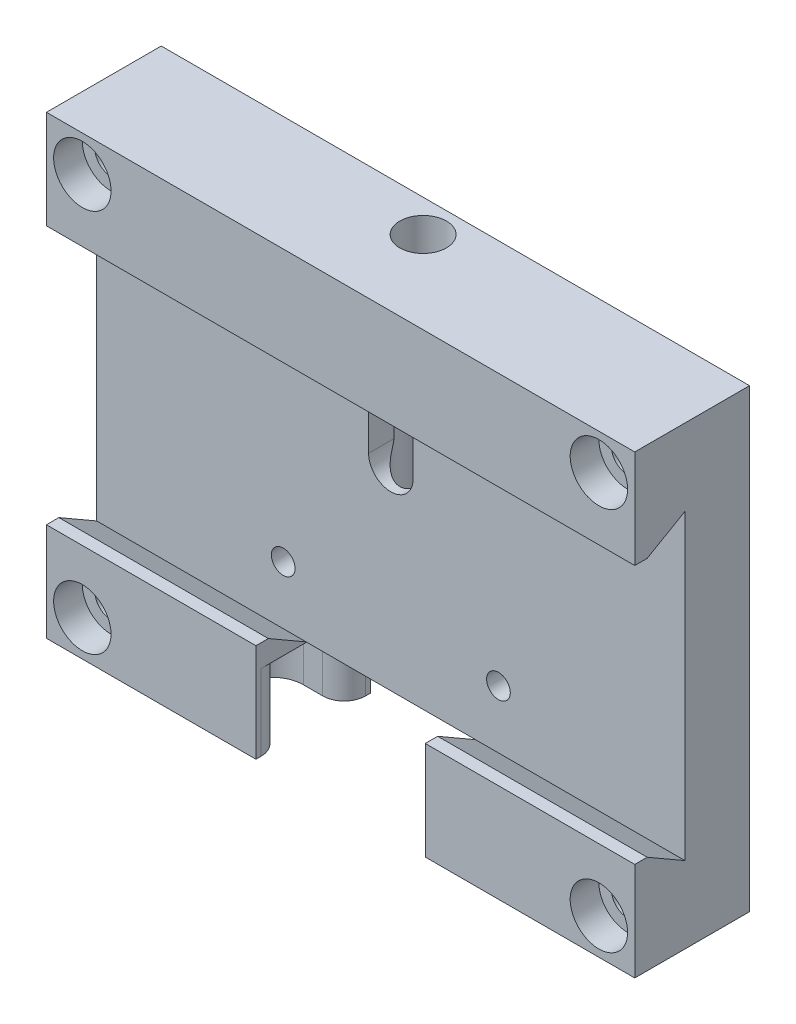
from build123d import *

# Parameters (mm, degrees)
SKETCH_1_W                  = 82
SKETCH_1_H                  = 63.5
EXTRUDE_1_DEPTH             = 16
CUT_EXTRUDE_1_DEPTH         = 83
SKETCH_15_W                 = 23.6
SKETCH_15_H                 = 14.711451884
CUT_EXTRUDE_4_DEPTH         = 7
SKETCH_16_W                 = 23.6
SKETCH_16_H                 = 10.67
CUT_EXTRUDE_5_DEPTH         = 9
SKETCH_17_R                 = 2.5
CUT_EXTRUDE_6_DEPTH         = 8
M4X0_72_D                   = 3.3
M4X0_72_DEPTH               = 10
M4X0_72_TIP                 = 0.991420021
CUT_EXTRUDE_7_DEPTH         = 4
SKETCH_26_R                 = 3.25
CUT_EXTRUDE_8_DEPTH         = 38
HOLE_WIZARD_M41_D           = 4.5
HOLE_WIZARD_M41_CBORE_D     = 8
HOLE_WIZARD_M41_CBORE_DEPTH = 4
CHAMFER_2_SIZE              = 1
CHAMFER_2_SIZE2             = 2
CHAMFER_2_PART_2_SIZE       = 1
CHAMFER_2_PART_2_SIZE2      = 2
CHAMFER_2_PART_3_SIZE       = 1
CHAMFER_2_PART_3_SIZE2      = 2
CUT_EXTRUDE_12_DEPTH        = 10.6
FILLET_1_R                  = 3
M4X0_73_D                   = 3.3


with BuildPart() as part:
    # Эскиз1 → Бобышка-Вытянуть1 (new body)
    with BuildSketch(Plane.XY):
        with Locations((41, -31.75)):
            Rectangle(SKETCH_1_W, SKETCH_1_H)
    extrude(amount=EXTRUDE_1_DEPTH)

    # Эскиз2 → Вырез-Вытянуть1 (cut, through all)
    with BuildSketch(Plane.ZY):
        Polygon((9, -10.67), (16, -14.711451884), (16, -48.788548116), (9, -52.83), align=None)
    extrude(amount=-CUT_EXTRUDE_1_DEPTH, mode=Mode.SUBTRACT)

    # Эскиз15 → Вырез-Вытянуть4 (cut)
    with BuildSketch(Plane.XY.offset(16)):
        with Locations((41, -56.144274058)):
            Rectangle(SKETCH_15_W, SKETCH_15_H)
    extrude(amount=-CUT_EXTRUDE_4_DEPTH, mode=Mode.SUBTRACT)

    # Эскиз16 → Вырез-Вытянуть5 (cut)
    with BuildSketch(Plane.XY.offset(9)):
        with Locations((41, -58.165)):
            Rectangle(SKETCH_16_W, SKETCH_16_H)
    extrude(amount=-CUT_EXTRUDE_5_DEPTH, mode=Mode.SUBTRACT)

    # Эскиз17 → Вырез-Вытянуть6 (cut)
    with BuildSketch(Plane.XZ.offset(52.83)):
        with Locations((33.5, 5)):
            Circle(SKETCH_17_R)
        with Locations((48.5, 5)):
            Circle(SKETCH_17_R)
    extrude(amount=-CUT_EXTRUDE_6_DEPTH, mode=Mode.SUBTRACT)

    # Отверстие обработанное метчиком M4x0.72
    with Locations(Plane(origin=(0, -52.83, 0), x_dir=(-1, 0, 0), z_dir=(0, -1, 0))):
        with Locations((-41, -5)):
            Hole(M4X0_72_D / 2, depth=M4X0_72_DEPTH)
            with Locations((0, 0, -(M4X0_72_DEPTH + M4X0_72_TIP / 2))):  # 118° drill point
                Cone(0, M4X0_72_D / 2, M4X0_72_TIP, mode=Mode.SUBTRACT)

    # Эскиз25 → Вырез-Вытянуть7 (cut)
    with BuildSketch(Plane.XY.offset(9)):
        with BuildLine():
            Line((44.1, -18.711451884), (44.1, -25.711451884))
            ThreePointArc((44.1, -25.711451884), (41, -28.811451884), (37.9, -25.711451884))
            Line((37.9, -25.711451884), (37.9, -18.711451884))
            ThreePointArc((37.9, -18.711451884), (41, -15.611451884), (44.1, -18.711451884))
        make_face()
    extrude(amount=-CUT_EXTRUDE_7_DEPTH, mode=Mode.SUBTRACT)

    # Эскиз26 → Вырез-Вытянуть8 (cut)
    with BuildSketch(Plane(origin=(0, 0, 0), x_dir=(1, 0, 0), z_dir=(0, 1, 0))):
        with Locations((41, -4.5)):
            Circle(SKETCH_26_R)
    extrude(amount=-CUT_EXTRUDE_8_DEPTH, mode=Mode.SUBTRACT)

    # Цековка для винта с внутренним шестигранником M41 (through all)
    with Locations(Plane(origin=(30.759227947, 26.793365177, 16), x_dir=(-1, 0, 0), z_dir=(0, 0, 1))):
        with Locations((-46.240772053, 31.793365177), (-46.240772053, 85.293365177), (25.759227947, 85.293365177), (25.759227947, 31.793365177)):
            CounterBoreHole(HOLE_WIZARD_M41_D / 2, HOLE_WIZARD_M41_CBORE_D / 2, HOLE_WIZARD_M41_CBORE_DEPTH)

    # Фаска2
    chamfer_2_edges = [part.edges().sort_by_distance(p)[0] for p in [
        (41, -14.711451884, 16),
    ]]
    chamfer_2_side = [part.faces().sort_by_distance(p)[0] for p in [
        (41, -7.569889145, 16),
    ]]
    chamfer(chamfer_2_edges, length=CHAMFER_2_SIZE, length2=CHAMFER_2_SIZE2, reference=chamfer_2_side[0])

    # Фаска2 part 2
    chamfer_2_part_2_edges = [part.edges().sort_by_distance(p)[0] for p in [
        (67.4, -48.788548116, 16),
    ]]
    chamfer_2_part_2_side = [part.faces().sort_by_distance(p)[0] for p in [
        (66.127821531, -55.832096576, 16),
    ]]
    chamfer(chamfer_2_part_2_edges, length=CHAMFER_2_PART_2_SIZE, length2=CHAMFER_2_PART_2_SIZE2, reference=chamfer_2_part_2_side[0])

    # Фаска2 part 3
    chamfer_2_part_3_edges = [part.edges().sort_by_distance(p)[0] for p in [
        (14.6, -48.788548116, 16),
    ]]
    chamfer_2_part_3_side = [part.faces().sort_by_distance(p)[0] for p in [
        (15.872178469, -55.832096576, 16),
    ]]
    chamfer(chamfer_2_part_3_edges, length=CHAMFER_2_PART_3_SIZE, length2=CHAMFER_2_PART_3_SIZE2, reference=chamfer_2_part_3_side[0])

    # Эскиз32 → Вырез-Вытянуть12 (cut)
    with BuildSketch(Plane.XZ.offset(63.5)):
        with BuildLine():
            Line((52.7, -0.2), (52.7, 3.7))
            Line((52.7, 3.7), (58.5, 3.7))
            ThreePointArc((58.5, 3.7), (62.8, 8), (58.5, 12.3))
            Line((58.5, 12.3), (52.7, 12.3))
            Line((52.7, 12.3), (52.7, 16.2))
            Line((52.7, 16.2), (29.3, 16.2))
            Line((29.3, 16.2), (29.3, 12.3))
            Line((29.3, 12.3), (23.5, 12.3))
            ThreePointArc((23.5, 12.3), (19.2, 8), (23.5, 3.7))
            Line((23.5, 3.7), (29.3, 3.7))
            Line((29.3, 3.7), (29.3, -0.2))
            Line((29.3, -0.2), (52.7, -0.2))
        make_face()
    extrude(amount=-CUT_EXTRUDE_12_DEPTH, mode=Mode.SUBTRACT)

    # Скругление1
    fillet_1_edges = [part.edges().sort_by_distance(p)[0] for p in [
        (52.8, -58.2, 3.7),
        (52.8, -58.2, 12.3),
        (29.2, -58.2, 12.3),
        (29.2, -58.2, 3.7),
    ]]
    fillet(fillet_1_edges, radius=FILLET_1_R)

    # Отверстие обработанное метчиком M4x0.73 (through all)
    with Locations(Plane(origin=(0, 0, 0), x_dir=(-1, 0, 0), z_dir=(0, 0, -1))):
        with Locations((-26, -44.75), (-26, -18.75), (-56, -18.75), (-56, -44.75)):
            Hole(M4X0_73_D / 2)


solid = part.part
